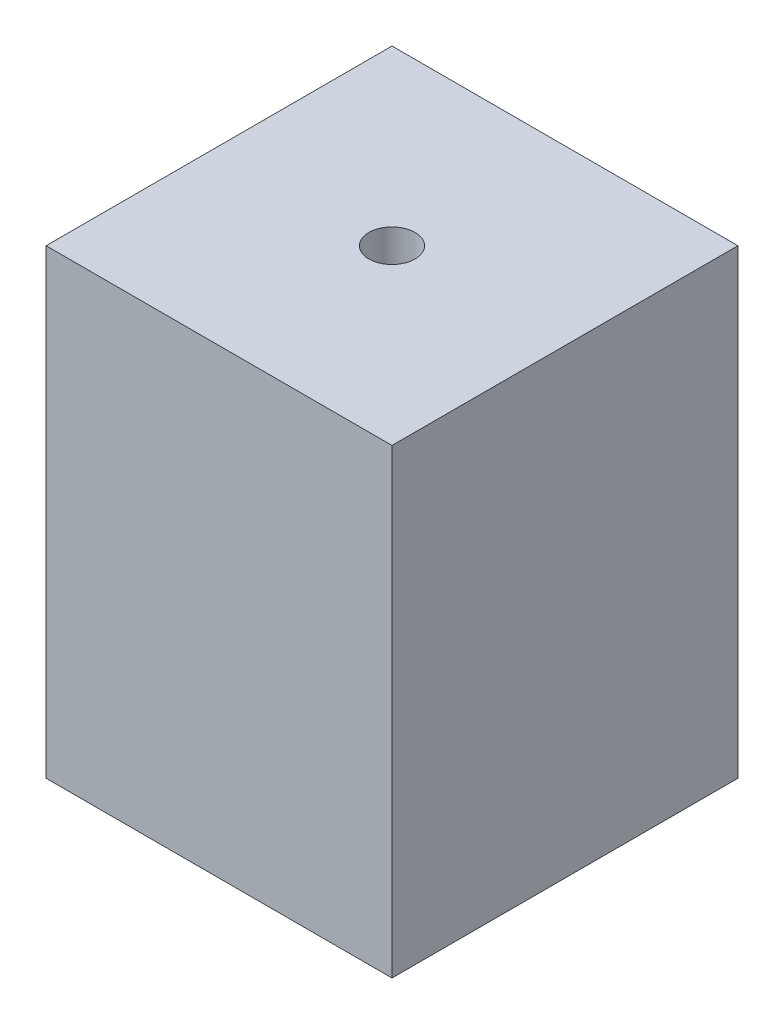
from build123d import *

# Parameters (mm, degrees)
SKETCH1_W           = 38.1
SKETCH1_H           = 38.1
BOSS_EXTRUDE1_DEPTH = 50.8
SKETCH2_R           = 2.54
CUT_EXTRUDE1_DEPTH  = 6.35


with BuildPart() as part:
    # Sketch1 → Boss-Extrude1 (new body)
    with BuildSketch(Plane(origin=(0, 0, 0), x_dir=(1, 0, 0), z_dir=(0, 1, 0))):
        with Locations((19.05, 19.05)):
            Rectangle(SKETCH1_W, SKETCH1_H)
    extrude(amount=BOSS_EXTRUDE1_DEPTH)

    # Sketch2 → Cut-Extrude1 (cut)
    with BuildSketch(Plane(origin=(0, 50.8, 0), x_dir=(1, 0, 0), z_dir=(0, 1, 0))):
        with Locations((19.05, 19.05)):
            Circle(SKETCH2_R)
    extrude(amount=-CUT_EXTRUDE1_DEPTH, mode=Mode.SUBTRACT)


solid = part.part
